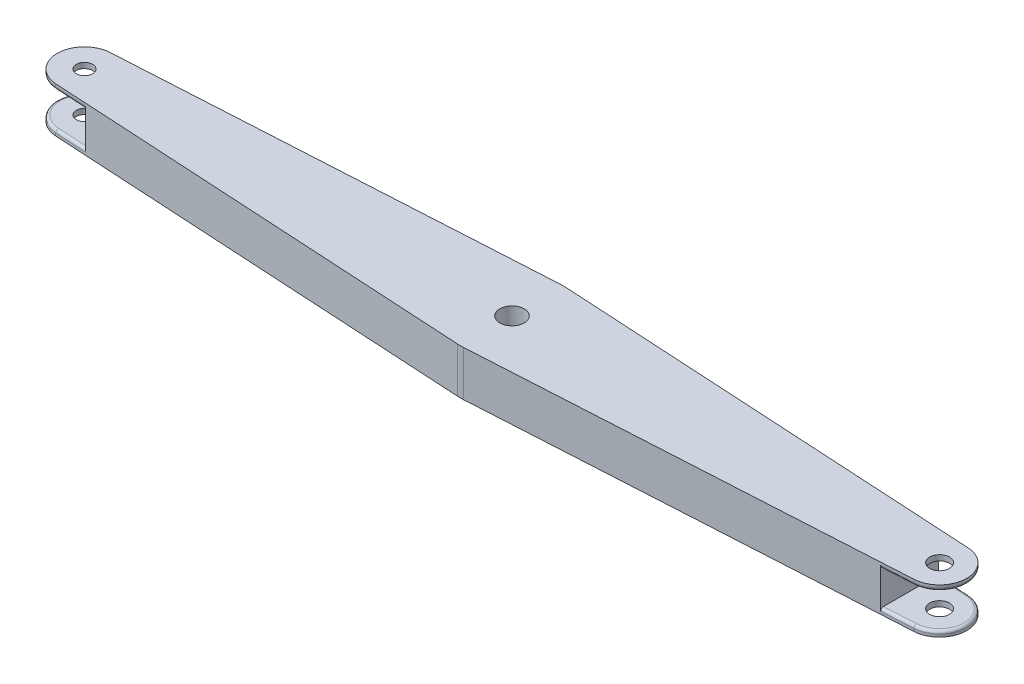
from build123d import *

# Parameters (mm, degrees)
SKETCH1_R           = 18
SKETCH1_R_2         = 3
SKETCH1_R_3         = 3.628209061
BOSS_EXTRUDE1_DEPTH = 16.65
SKETCH2_W           = 30
SKETCH2_H           = 12.65
CUT_EXTRUDE2_DEPTH  = 11
CUT_EXTRUDE3_REACH  = 171.197
SKETCH3_R           = 4.5
FILLET2_R           = 1


with BuildPart() as part:
    # Sketch1 → Boss-Extrude1 (new body)
    with BuildSketch(Plane(origin=(0, 0, 0), x_dir=(1, 0, 0), z_dir=(0, 1, 0))):
        with BuildLine():
            Line((-1.087094723, -18.968875166), (-157.872155118, -9.983618508))
            ThreePointArc((-157.872155118, -9.983618508), (-167.3, 0), (-157.872155118, 9.983618508))
            Line((-157.872155118, 9.983618508), (-1.087094723, 18.968875166))
            ThreePointArc((-1.087094723, 18.968875166), (0, 19), (1.087094723, 18.968875166))
            Line((1.087094723, 18.968875166), (157.872155118, 9.983618508))
            ThreePointArc((157.872155118, 9.983618508), (167.3, 0), (157.872155118, -9.983618508))
            Line((157.872155118, -9.983618508), (1.087094723, -18.968875166))
            ThreePointArc((1.087094723, -18.968875166), (0, -19), (-1.087094723, -18.968875166))
        make_face()
        Circle(SKETCH1_R, mode=Mode.SUBTRACT)
        with Locations(Location((-157.3, 0, 0), (0, 0, 270))):
            Circle(SKETCH1_R_2, mode=Mode.SUBTRACT)
        with Locations(Location((157.3, 0, 0), (0, 0, 270))):
            Circle(SKETCH1_R_3, mode=Mode.SUBTRACT)
        Circle(SKETCH1_R)
    extrude(amount=BOSS_EXTRUDE1_DEPTH)

    # Sketch2 → Cut-Extrude2 (cut, symmetric)
    with BuildSketch(Plane(origin=(-157.3, 0, 0), x_dir=(0, 0, -1), z_dir=(1, 0, 0))):
        with Locations((0, 8.325)):
            Rectangle(SKETCH2_W, SKETCH2_H)
    cut_extrude2 = extrude(amount=CUT_EXTRUDE2_DEPTH, both=True, mode=Mode.SUBTRACT)

    # Mirror1: Cut-Extrude2 across plane
    add(cut_extrude2.mirror(Plane(origin=(0, 0, 0), x_dir=(0, 0, 1), z_dir=(1, 0, 0))), mode=Mode.SUBTRACT)

    # Sketch3 → Cut-Extrude3 (cut, up to next)
    with BuildSketch(Plane(origin=(0, 16.65, 0), x_dir=(1, 0, 0), z_dir=(0, 1, 0)), mode=Mode.PRIVATE) as cut_extrude3_sk1:
        with Locations(Location((0, 0, 0), (0, 0, 270))):
            Circle(SKETCH3_R)
    cut_extrude3_tool1 = extrude(cut_extrude3_sk1.sketch, amount=-CUT_EXTRUDE3_REACH, mode=Mode.PRIVATE) & part.part
    add(cut_extrude3_tool1.solids().sort_by_distance((0, 16.65, 0))[0], mode=Mode.SUBTRACT)

    # Fillet2
    fillet2_edges = [part.edges().sort_by_distance(p)[0] for p in [
        (-167.3, 2, 0),
        (-167.3, 14.65, 0),
        (-152.086077559, 14.65, 10.315215102),
        (-152.086077559, 2, 10.315215102),
        (-152.086077559, 14.65, -10.315215102),
        (-152.086077559, 2, -10.315215102),
        (152.086077559, 2, -10.315215102),
        (167.3, 2, 0),
        (167.3, 14.65, 0),
        (152.086077559, 14.65, -10.315215102),
        (152.086077559, 2, 10.315215102),
        (152.086077559, 14.65, 10.315215102),
    ]]
    fillet(fillet2_edges, radius=FILLET2_R)


solid = part.part
